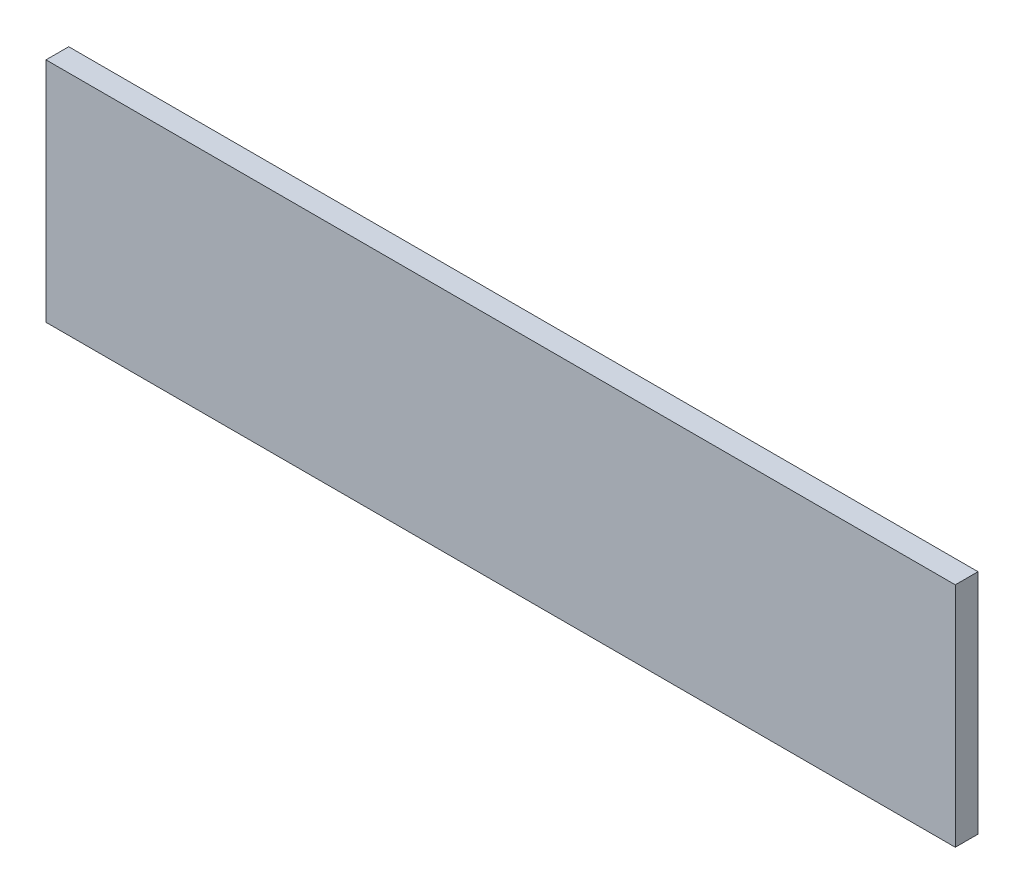
from build123d import *

# Parameters (mm, degrees)
SKETCH1_W           = 400
SKETCH1_H           = 100
BOSS_EXTRUDE1_DEPTH = 10
SKETCH2_R           = 20
CUT_EXTRUDE1_DEPTH  = 0.5


with BuildPart() as part:
    # Sketch1 → Boss-Extrude1 (new body)
    with BuildSketch(Plane.XY):
        Rectangle(SKETCH1_W, SKETCH1_H)
    extrude(amount=BOSS_EXTRUDE1_DEPTH)

    # Sketch2 → Cut-Extrude1 (cut)
    with BuildSketch(Plane(origin=(0, 0, 0), x_dir=(-1, 0, 0), z_dir=(0, 0, -1))):
        Circle(SKETCH2_R)
    extrude(amount=-CUT_EXTRUDE1_DEPTH, mode=Mode.SUBTRACT)


solid = part.part
